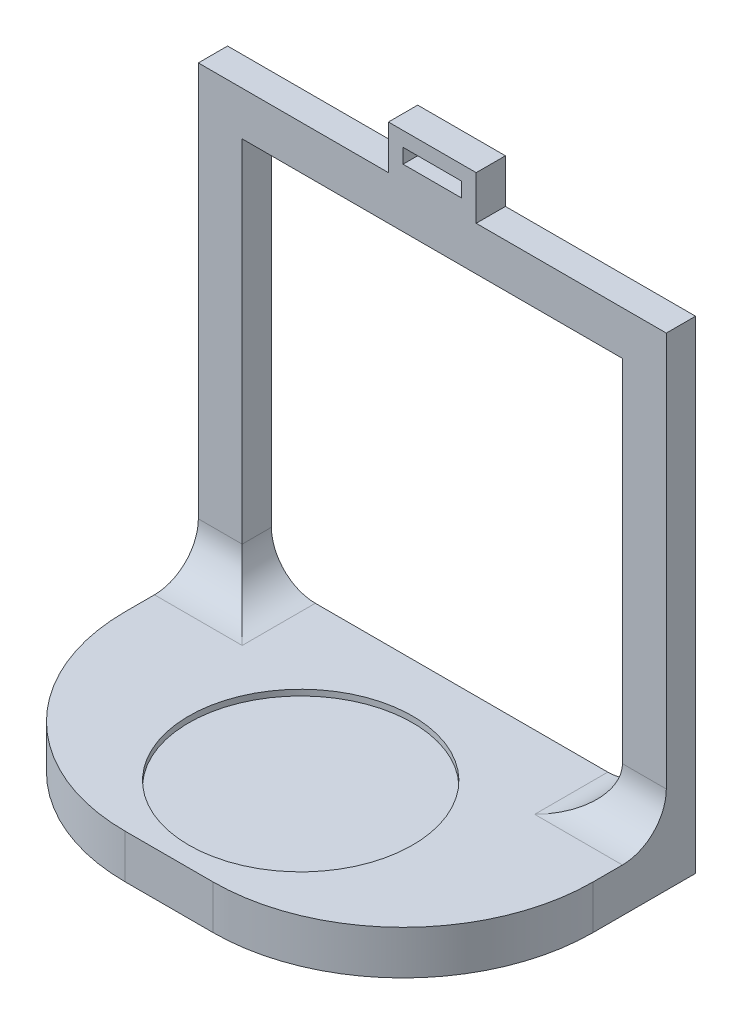
from build123d import *

# Parameters (mm, degrees)
SKETCH_1_W          = 20
SKETCH_1_H          = 5
SKETCH_1_W_2        = 130
SKETCH_1_H_2        = 135
EXTRUDE_1_DEPTH     = 10
SKETCH_2_W          = 160
SKETCH_2_H          = 15
EXTRUDE_2_DEPTH     = 90
SKETCH_3_R          = 38.25
CUT_EXTRUDE_1_DEPTH = 2
FILLET_1_R          = 15
FILLET_2_R          = 15
FILLET_3_R          = 65


with BuildPart() as part:
    # 草图1 → 凸台-拉伸1 (new body)
    with BuildSketch(Plane.XY):
        Polygon((0, 0), (30, 0), (30, -15), (95, -15), (95, -180), (-65, -180), (-65, -15), (0, -15), align=None)
        with Locations((15, -7.5)):
            Rectangle(SKETCH_1_W, SKETCH_1_H, mode=Mode.SUBTRACT)
        with Locations((15, -97.5)):
            Rectangle(SKETCH_1_W_2, SKETCH_1_H_2, mode=Mode.SUBTRACT)
    extrude(amount=EXTRUDE_1_DEPTH)

    # 草图2 → 凸台-拉伸2 (add)
    with BuildSketch(Plane.XY.offset(10)):
        with Locations((15, -172.5)):
            Rectangle(SKETCH_2_W, SKETCH_2_H)
    extrude(amount=EXTRUDE_2_DEPTH)

    # 草图3 → 切除-拉伸1 (cut)
    with BuildSketch(Plane(origin=(0, -165, 0), x_dir=(1, 0, 0), z_dir=(0, 1, 0))):
        with Locations((15, -55)):
            Circle(SKETCH_3_R)
    extrude(amount=-CUT_EXTRUDE_1_DEPTH, mode=Mode.SUBTRACT)

    # 圆角1
    fillet_1_edges = [part.edges().sort_by_distance(p)[0] for p in [
        (-57.5, -165, 10),
        (87.5, -165, 10),
    ]]
    fillet(fillet_1_edges, radius=FILLET_1_R)

    # 圆角2
    fillet_2_edges = [part.edges().sort_by_distance(p)[0] for p in [
        (-50, -165, 17.5),
        (80, -165, 17.5),
    ]]
    fillet(fillet_2_edges, radius=FILLET_2_R)

    # 圆角3
    fillet_3_edges = [part.edges().sort_by_distance(p)[0] for p in [
        (-65, -172.5, 100),
        (95, -172.5, 100),
    ]]
    fillet(fillet_3_edges, radius=FILLET_3_R)


solid = part.part
